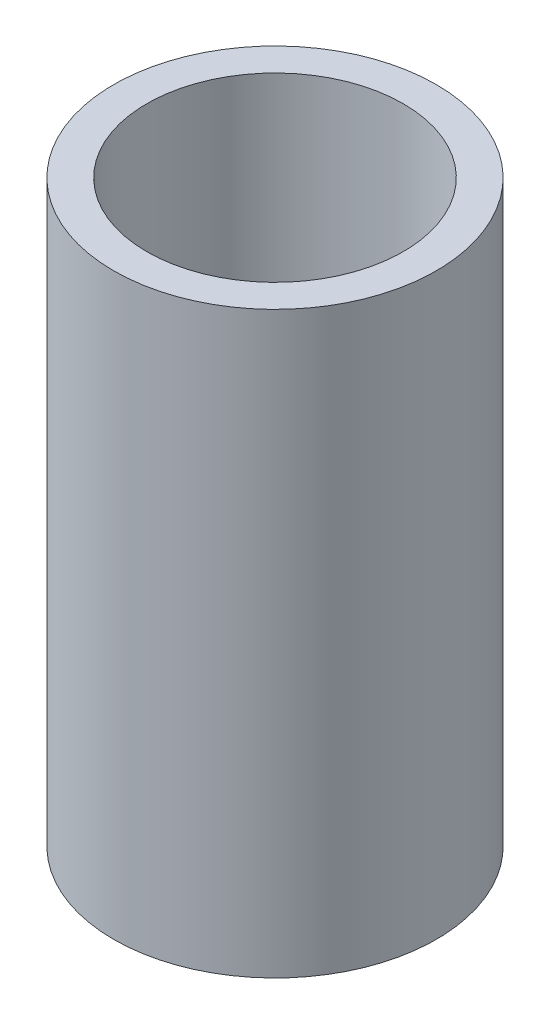
from build123d import *

# Parameters (mm, degrees)
SKETCH1_R           = 9.75
SKETCH1_R_2         = 7.75
BOSS_EXTRUDE1_DEPTH = 35


with BuildPart() as part:
    # Sketch1 → Boss-Extrude1 (new body)
    with BuildSketch(Plane(origin=(0, 0, 0), x_dir=(1, 0, 0), z_dir=(0, 1, 0))):
        Circle(SKETCH1_R)
        Circle(SKETCH1_R_2, mode=Mode.SUBTRACT)
    extrude(amount=BOSS_EXTRUDE1_DEPTH)


solid = part.part
